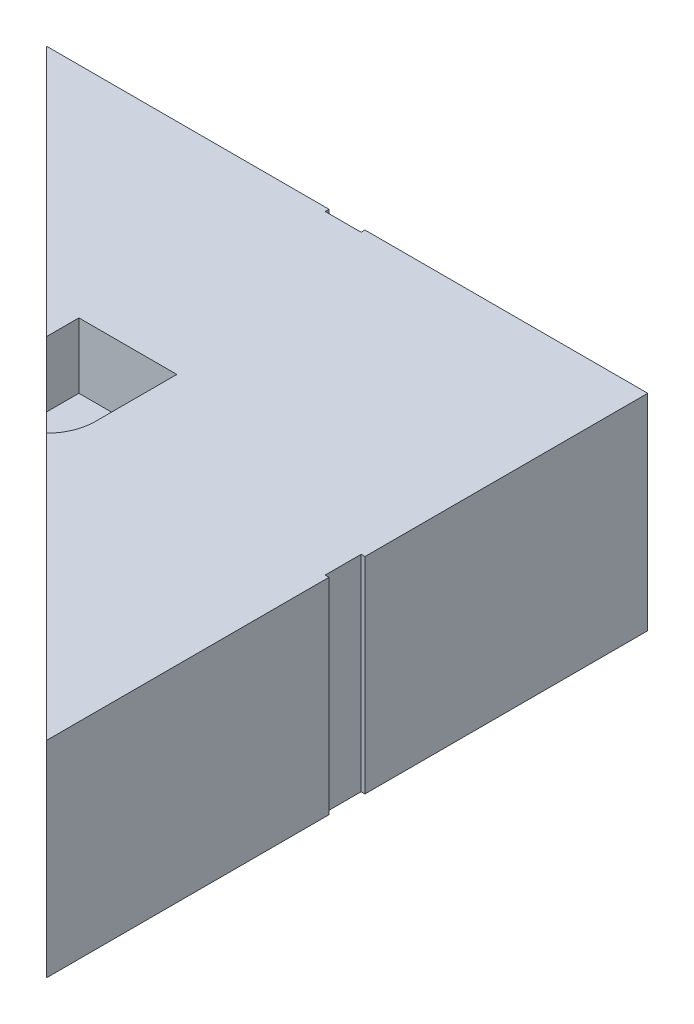
from build123d import *

# Parameters (mm, degrees)
SKETCH1_W           = 117
SKETCH1_H           = 117
BOSS_EXTRUDE1_DEPTH = 40
SKETCH2_W           = 10.53028371
SKETCH2_H           = 7.9375
CUT_EXTRUDE1_DEPTH  = 12.7
SKETCH7_W           = 7
SKETCH7_H           = 1.5
CUT_EXTRUDE5_DEPTH  = 171.22925718
CIRPATTERN3_COUNT   = 3
CIRPATTERN3_ANGLE   = 180
CUT_EXTRUDE12_DEPTH = 171.22925718


with BuildPart() as part:
    # Sketch1 → Boss-Extrude1 (new body)
    with BuildSketch(Plane(origin=(0, 0, 0), x_dir=(1, 0, 0), z_dir=(0, 1, 0))):
        with Locations((58.5, 58.5)):
            Rectangle(SKETCH1_W, SKETCH1_H)
    extrude(amount=BOSS_EXTRUDE1_DEPTH)

    # Sketch2 → Cut-Extrude1 (cut)
    with BuildSketch(Plane(origin=(0, 40, 0), x_dir=(1, 0, 0), z_dir=(0, 1, 0))):
        with BuildLine():
            ThreePointArc((63.765141855, 66.4375), (66.892737967, 63.004173), (68.025, 58.5))
            Line((68.025, 58.5), (68.025, 74.375))
            Line((68.025, 74.375), (48.975, 74.375))
            Line((48.975, 74.375), (48.975, 58.5))
            ThreePointArc((48.975, 58.5), (50.107262033, 63.004173), (53.234858145, 66.4375))
            ThreePointArc((53.234858145, 66.4375), (58.5, 68.025), (63.765141855, 66.4375))
        make_face()
        with BuildLine():
            ThreePointArc((63.765141855, 50.5625), (66.892737967, 53.995827), (68.025, 58.5))
            Line((68.025, 58.5), (63.765141855, 58.5))
            Line((63.765141855, 58.5), (63.765141855, 50.5625))
        make_face()
        with BuildLine():
            Line((63.765141855, 58.5), (68.025, 58.5))
            ThreePointArc((68.025, 58.5), (66.892737967, 63.004173), (63.765141855, 66.4375))
            Line((63.765141855, 66.4375), (63.765141855, 58.5))
        make_face()
        with BuildLine():
            Line((53.234858145, 50.5625), (53.234858145, 58.5))
            Line((53.234858145, 58.5), (48.975, 58.5))
            ThreePointArc((48.975, 58.5), (50.107262033, 53.995827), (53.234858145, 50.5625))
        make_face()
        with BuildLine():
            Line((48.975, 58.5), (53.234858145, 58.5))
            Line((53.234858145, 58.5), (53.234858145, 66.4375))
            ThreePointArc((53.234858145, 66.4375), (50.107262033, 63.004173), (48.975, 58.5))
        make_face()
        with Locations((58.5, 62.46875)):
            Rectangle(SKETCH2_W, SKETCH2_H)
        with BuildLine():
            Line((53.234858145, 66.4375), (63.765141855, 66.4375))
            ThreePointArc((63.765141855, 66.4375), (58.5, 68.025), (53.234858145, 66.4375))
        make_face()
        with BuildLine():
            ThreePointArc((63.765141855, 50.5625), (66.892737967, 53.995827), (68.025, 58.5))
            Line((68.025, 58.5), (63.765141855, 58.5))
            Line((63.765141855, 58.5), (63.765141855, 50.5625))
        make_face()
        with BuildLine():
            Line((63.765141855, 58.5), (68.025, 58.5))
            ThreePointArc((68.025, 58.5), (66.892737967, 63.004173), (63.765141855, 66.4375))
            Line((63.765141855, 66.4375), (63.765141855, 58.5))
        make_face()
        with BuildLine():
            Line((53.234858145, 50.5625), (53.234858145, 58.5))
            Line((53.234858145, 58.5), (48.975, 58.5))
            ThreePointArc((48.975, 58.5), (50.107262033, 53.995827), (53.234858145, 50.5625))
        make_face()
        with BuildLine():
            Line((48.975, 58.5), (53.234858145, 58.5))
            Line((53.234858145, 58.5), (53.234858145, 66.4375))
            ThreePointArc((53.234858145, 66.4375), (50.107262033, 63.004173), (48.975, 58.5))
        make_face()
        with Locations((58.5, 54.53125)):
            Rectangle(SKETCH2_W, SKETCH2_H)
    extrude(amount=-CUT_EXTRUDE1_DEPTH, mode=Mode.SUBTRACT)

    # Sketch7 → Cut-Extrude5 (cut, through all)
    with BuildSketch(Plane.XZ):
        with Locations((58.5, -117)):
            Rectangle(SKETCH7_W, SKETCH7_H)
    cut_extrude5 = extrude(amount=-CUT_EXTRUDE5_DEPTH, mode=Mode.SUBTRACT)

    # CirPattern3: Cut-Extrude5 ×3 about axis
    cirpattern3_axis = Axis((58.5, 0, -58.5), (0, -1, 0))
    for i in range(1, CIRPATTERN3_COUNT):
        add(cut_extrude5.rotate(cirpattern3_axis, i * CIRPATTERN3_ANGLE / (CIRPATTERN3_COUNT - 1)), mode=Mode.SUBTRACT)

    # Sketch11 → Cut-Extrude12 (cut, through all)
    with BuildSketch(Plane.XZ):
        Polygon((0, -117), (117, 0), (54.653996097, 62.346003903), (-62.346003903, -54.653996097), align=None)
    extrude(amount=-CUT_EXTRUDE12_DEPTH, mode=Mode.SUBTRACT)


solid = part.part
